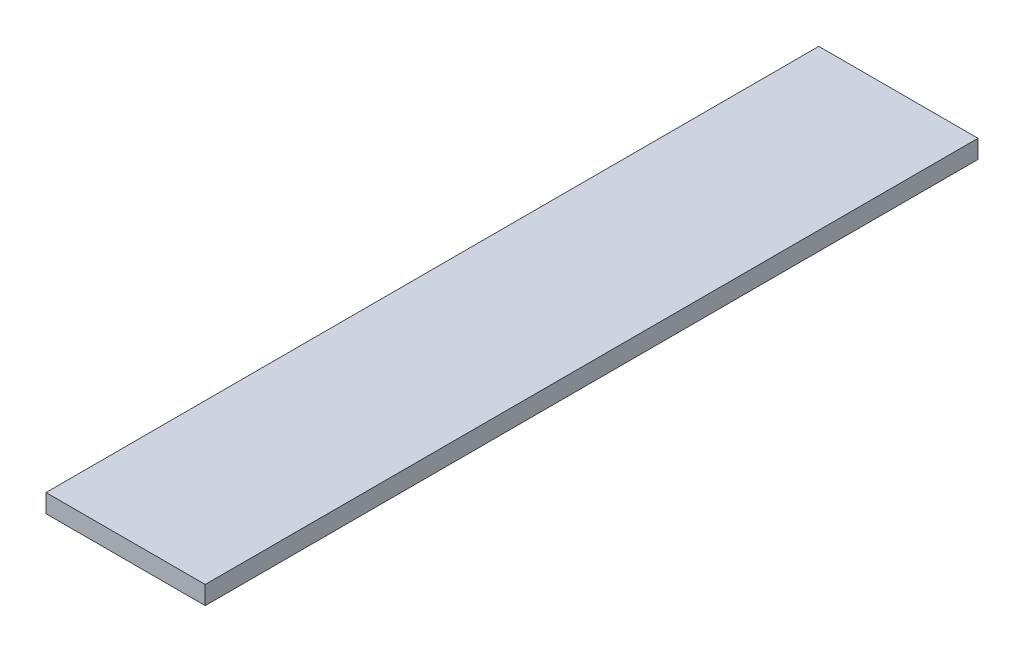
from build123d import *

# Parameters (mm, degrees)
CROQUIS1_W              = 26
CROQUIS1_H              = 126.2
SALIENTE_EXTRUIR1_DEPTH = 3


with BuildPart() as part:
    # Croquis1 → Saliente-Extruir1 (new body)
    with BuildSketch(Plane(origin=(0, 0, 0), x_dir=(1, 0, 0), z_dir=(0, 1, 0))):
        with Locations((13, 63.1)):
            Rectangle(CROQUIS1_W, CROQUIS1_H)
    extrude(amount=SALIENTE_EXTRUIR1_DEPTH)


solid = part.part
